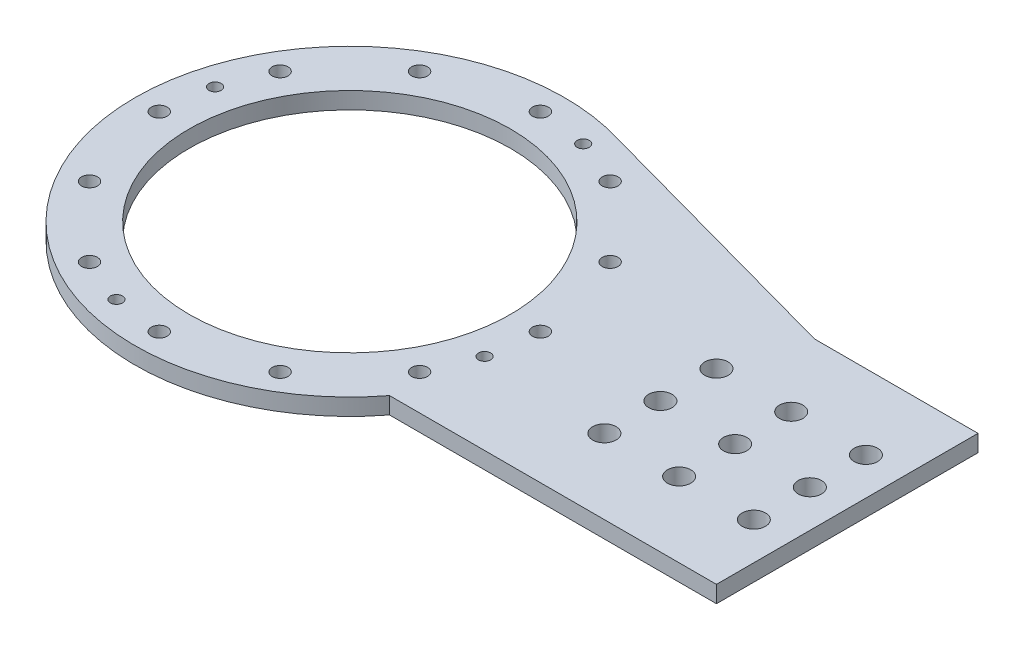
from build123d import *

# Parameters (mm, degrees)
SKETCH1_R           = 57.5
BOSS_EXTRUDE1_DEPTH = 4.5
SKETCH2_W           = 140
SKETCH2_H           = 70
BOSS_EXTRUDE2_DEPTH = 4.5
BOSS_EXTRUDE3_DEPTH = 4.5
SKETCH4_R           = 43
CUT_EXTRUDE1_DEPTH  = 5.5
SKETCH7_R           = 3.125
CUT_EXTRUDE8_DEPTH  = 5.5
LPATTERN1_COUNT     = 3
LPATTERN1_PITCH     = 20
CUT_EXTRUDE5_START  = -1
SKETCH5_R           = 2.125
CUT_EXTRUDE5_DEPTH  = 6.5
CIRPATTERN1_COUNT   = 12
SKETCH12_R          = 1.625
CUT_EXTRUDE17_DEPTH = 5.5
CIRPATTERN2_COUNT   = 4
SKETCH13_R          = 3.125
CUT_EXTRUDE18_DEPTH = 10
LPATTERN2_COUNT     = 3
LPATTERN2_PITCH     = 20


with BuildPart() as part:
    # Sketch1 → Boss-Extrude1 (new body)
    with BuildSketch(Plane(origin=(0, 0, 0), x_dir=(1, 0, 0), z_dir=(0, 1, 0))):
        Circle(SKETCH1_R)
    extrude(amount=BOSS_EXTRUDE1_DEPTH)

    # Sketch2 → Boss-Extrude2 (add)
    with BuildSketch(Plane(origin=(0, 0, 0), x_dir=(1, 0, 0), z_dir=(0, 1, 0))):
        with Locations((63.125798099, 0)):
            Rectangle(SKETCH2_W, SKETCH2_H)
    extrude(amount=BOSS_EXTRUDE2_DEPTH)

    # Sketch3 → Boss-Extrude3 (add)
    with BuildSketch(Plane(origin=(0, 0, 0), x_dir=(1, 0, 0), z_dir=(0, 1, 0))):
        Polygon((89.373258538, 35), (13.76852627, 55.827212758), (13.76852627, 13.558751548), align=None)
    extrude(amount=BOSS_EXTRUDE3_DEPTH)

    # Sketch4 → Cut-Extrude1 (cut, through all)
    with BuildSketch(Plane(origin=(0, 4.5, 0), x_dir=(1, 0, 0), z_dir=(0, 1, 0))):
        Circle(SKETCH4_R)
    extrude(amount=-CUT_EXTRUDE1_DEPTH, mode=Mode.SUBTRACT)

    # Sketch7 → Cut-Extrude8 (cut, through all)
    with BuildSketch(Plane(origin=(0, 4.5, 0), x_dir=(1, 0, 0), z_dir=(0, 1, 0))):
        with Locations((123.125798099, 15)):
            Circle(SKETCH7_R)
        with Locations((123.125798099, -15)):
            Circle(SKETCH7_R)
    cut_extrude8 = extrude(amount=-CUT_EXTRUDE8_DEPTH, mode=Mode.SUBTRACT)

    # LPattern1: Cut-Extrude8 ×3
    with Locations(*[(-i * LPATTERN1_PITCH, 0, 0) for i in range(1, LPATTERN1_COUNT)]):
        add(cut_extrude8, mode=Mode.SUBTRACT)

    # Sketch5 → Cut-Extrude5 (cut)
    with BuildSketch(Plane(origin=(0, 0, 0), x_dir=(1, 0, 0), z_dir=(0, 1, 0)).offset(CUT_EXTRUDE5_START)):
        with Locations((-51, 0)):
            Circle(SKETCH5_R)
    cut_extrude5 = extrude(amount=CUT_EXTRUDE5_DEPTH, mode=Mode.SUBTRACT)

    # CirPattern1: Cut-Extrude5 ×12 about axis
    cirpattern1_axis = Axis((0, 0, 0), (0, 1, 0))
    for i in range(1, CIRPATTERN1_COUNT):
        add(cut_extrude5.rotate(cirpattern1_axis, i * 360 / CIRPATTERN1_COUNT), mode=Mode.SUBTRACT)

    # Sketch12 → Cut-Extrude17 (cut, through all)
    with BuildSketch(Plane(origin=(0, 4.5, 0), x_dir=(1, 0, 0), z_dir=(0, 1, 0))):
        with Locations((-49.262217141, 13.1997713)):
            Circle(SKETCH12_R)
    cut_extrude17 = extrude(amount=-CUT_EXTRUDE17_DEPTH, mode=Mode.SUBTRACT)

    # CirPattern2: Cut-Extrude17 ×4 about axis
    cirpattern2_axis = Axis((0, 0, 0), (0, 1, 0))
    for i in range(1, CIRPATTERN2_COUNT):
        add(cut_extrude17.rotate(cirpattern2_axis, i * 360 / CIRPATTERN2_COUNT), mode=Mode.SUBTRACT)

    # Sketch13 → Cut-Extrude18 (cut)
    with BuildSketch(Plane(origin=(0, 4.5, 0), x_dir=(1, 0, 0), z_dir=(0, 1, 0))):
        with Locations((123.125798099, 0)):
            Circle(SKETCH13_R)
    cut_extrude18 = extrude(amount=-CUT_EXTRUDE18_DEPTH, mode=Mode.SUBTRACT)

    # LPattern2: Cut-Extrude18 ×3
    with Locations(*[(-i * LPATTERN2_PITCH, 0, 0) for i in range(1, LPATTERN2_COUNT)]):
        add(cut_extrude18, mode=Mode.SUBTRACT)


solid = part.part
